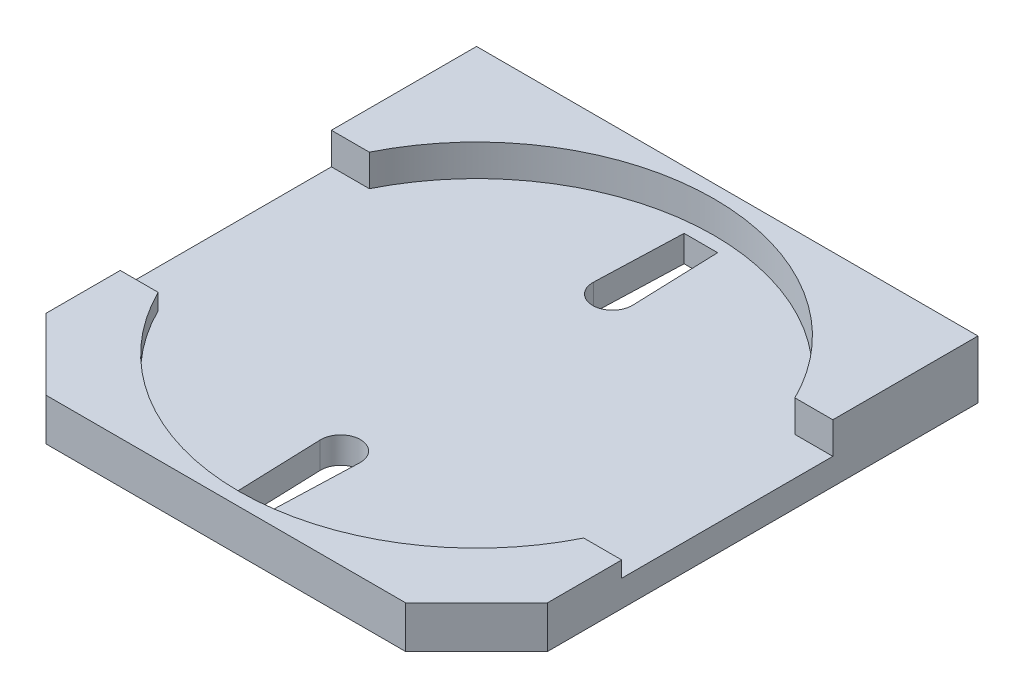
from build123d import *

# Parameters (mm, degrees)
SKETCH1_W           = 19
SKETCH1_H           = 19
BOSS_EXTRUDE1_DEPTH = 3.5
CUT_EXTRUDE1_DEPTH  = 4.5
CUT_EXTRUDE2_DEPTH  = 0.6
SKETCH5_W           = 19
SKETCH5_H           = 8
CUT_EXTRUDE3_DEPTH  = 0.6
SKETCH6_R           = 9
CUT_EXTRUDE4_DEPTH  = 1.2
SKETCH7_OUTSIDE_W   = 26.42
SKETCH7_OUTSIDE_H   = 26.42
SKETCH7_OUTSIDE_R   = 1.25
CUT_EXTRUDE5_DEPTH  = 1.3
CUT_EXTRUDE6_DEPTH  = 1
BOSS_EXTRUDE4_DEPTH = 1


with BuildPart() as part:
    # Sketch1 → Boss-Extrude1 (new body)
    with BuildSketch(Plane(origin=(0, 0, 0), x_dir=(1, 0, 0), z_dir=(0, 1, 0))):
        Rectangle(SKETCH1_W, SKETCH1_H)
    extrude(amount=BOSS_EXTRUDE1_DEPTH)

    # Sketch2 → Cut-Extrude1 (cut, through all)
    with BuildSketch(Plane(origin=(0, 3.5, 0), x_dir=(1, 0, 0), z_dir=(0, 1, 0))):
        Polygon((-9.5, -6.812994231), (-6.812994231, -9.5), (-9.5, -9.5), align=None)
    cut_extrude1 = extrude(amount=-CUT_EXTRUDE1_DEPTH, mode=Mode.SUBTRACT)

    # Mirror1: Cut-Extrude1 across plane
    add(cut_extrude1.mirror(Plane(origin=(0, 0, 0), x_dir=(0, 0, 1), z_dir=(1, 0, 0))), mode=Mode.SUBTRACT)

    # Sketch3 → Cut-Extrude2 (cut)
    with BuildSketch(Plane(origin=(0, 3.5, 0), x_dir=(1, 0, 0), z_dir=(0, 1, 0))):
        Polygon((-9.5, 4), (9.5, 4), (9.5, -6.812994231), (6.812994231, -9.5), (-6.812994231, -9.5), (-9.5, -6.812994231), align=None)
    extrude(amount=-CUT_EXTRUDE2_DEPTH, mode=Mode.SUBTRACT)

    # Sketch5 → Cut-Extrude3 (cut)
    with BuildSketch(Plane(origin=(0, 2.9, 0), x_dir=(1, 0, 0), z_dir=(0, 1, 0))):
        Rectangle(SKETCH5_W, SKETCH5_H)
    extrude(amount=-CUT_EXTRUDE3_DEPTH, mode=Mode.SUBTRACT)

    # Sketch6 → Cut-Extrude4 (cut)
    with BuildSketch(Plane(origin=(0, 3.5, 0), x_dir=(1, 0, 0), z_dir=(0, 1, 0))):
        Circle(SKETCH6_R)
    extrude(amount=-CUT_EXTRUDE4_DEPTH, mode=Mode.SUBTRACT)

    # Sketch7 outside → Cut-Extrude5 (cut)
    with BuildSketch(Plane.XZ):
        Rectangle(SKETCH7_OUTSIDE_W, SKETCH7_OUTSIDE_H)
        with Locations((-5.5, -6.20094747)):
            Circle(SKETCH7_OUTSIDE_R, mode=Mode.SUBTRACT)
        with Locations((-5.5, 5.29905253)):
            Circle(SKETCH7_OUTSIDE_R, mode=Mode.SUBTRACT)
        with Locations((5.5, 5.29905253)):
            Circle(SKETCH7_OUTSIDE_R, mode=Mode.SUBTRACT)
        with Locations((5.5, -6.20094747)):
            Circle(SKETCH7_OUTSIDE_R, mode=Mode.SUBTRACT)
    extrude(amount=-CUT_EXTRUDE5_DEPTH, mode=Mode.SUBTRACT)

    # Sketch8 → Cut-Extrude6 (cut)
    with BuildSketch(Plane.XZ.offset(-1.3)):
        with BuildLine():
            Line((-0.6, -9.5), (0.6, -9.5))
            Line((0.6, -9.5), (0.749551834, -5.175923885))
            ThreePointArc((0.749551834, -5.175923885), (0, -4.4), (-0.749551834, -5.175923885))
            Line((-0.749551834, -5.175923885), (-0.6, -9.5))
        make_face()
    cut_extrude6 = extrude(amount=-CUT_EXTRUDE6_DEPTH, mode=Mode.SUBTRACT)

    # Mirror2: Cut-Extrude6 across plane
    add(cut_extrude6.mirror(Plane.XY), mode=Mode.SUBTRACT)

    # Sketch11 → Boss-Extrude4 (add)
    with BuildSketch(Plane.XZ.offset(-1.3)):
        Polygon((-0.6, -9.5), (0.6, -9.5), (0.634585847, -8.5), (-0.634585847, -8.5), align=None)
    boss_extrude4 = extrude(amount=-BOSS_EXTRUDE4_DEPTH)

    # Mirror3: Boss-Extrude4 across plane
    add(boss_extrude4.mirror(Plane.XY))


solid = part.part
